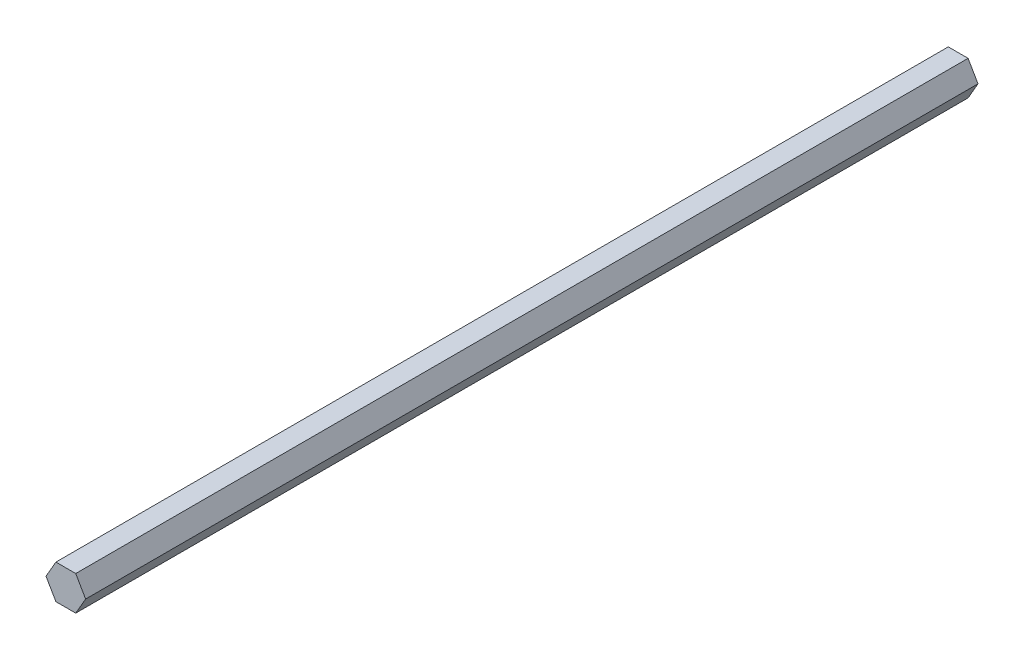
from build123d import *

# Parameters (mm, degrees)
BOSS_EXTRUDE1_DEPTH = 330.2


with BuildPart() as part:
    # Sketch1 → Boss-Extrude1 (new body)
    with BuildSketch(Plane.XY):
        Polygon((-3.666174209, 6.35), (-7.332348419, 0), (-3.666174209, -6.35), (3.666174209, -6.35), (7.332348419, 0), (3.666174209, 6.35), align=None)
    extrude(amount=BOSS_EXTRUDE1_DEPTH)


solid = part.part
